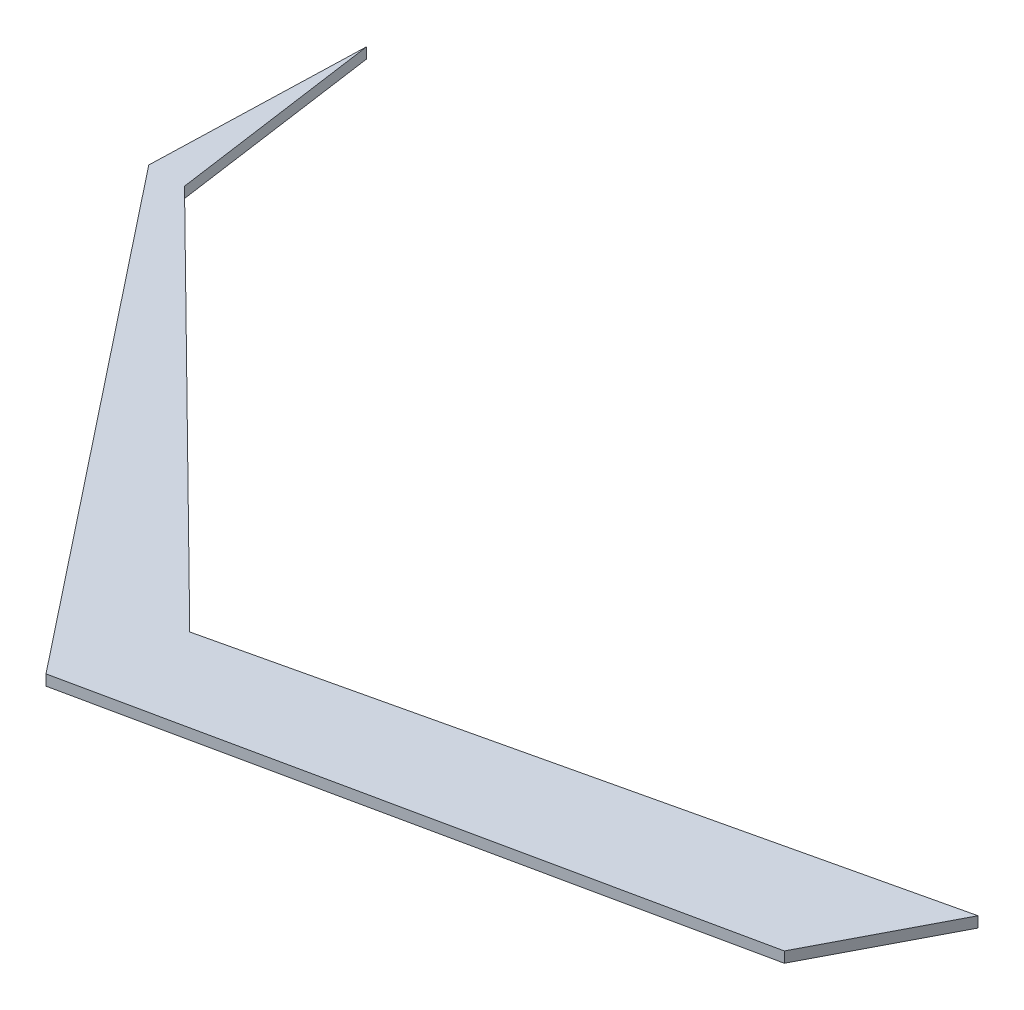
from build123d import *

# Parameters (mm, degrees)
BOSS_EXTRU_1_DEPTH = 2


with BuildPart() as part:
    # Esquisse1 → Boss.-Extru.1 (new body)
    with BuildSketch(Plane(origin=(0, 0, 0), x_dir=(1, 0, 0), z_dir=(0, 1, 0))):
        Polygon((-71.710934493, 131.755240155), (-72.927023173, 92.175888373), (0, 0), (114.087295212, 24.200945353), (126.521168393, 48.055055047), (6.662756585, 20.263553715), (-66.14023075, 92.083386076), align=None)
    extrude(amount=BOSS_EXTRU_1_DEPTH)


solid = part.part
